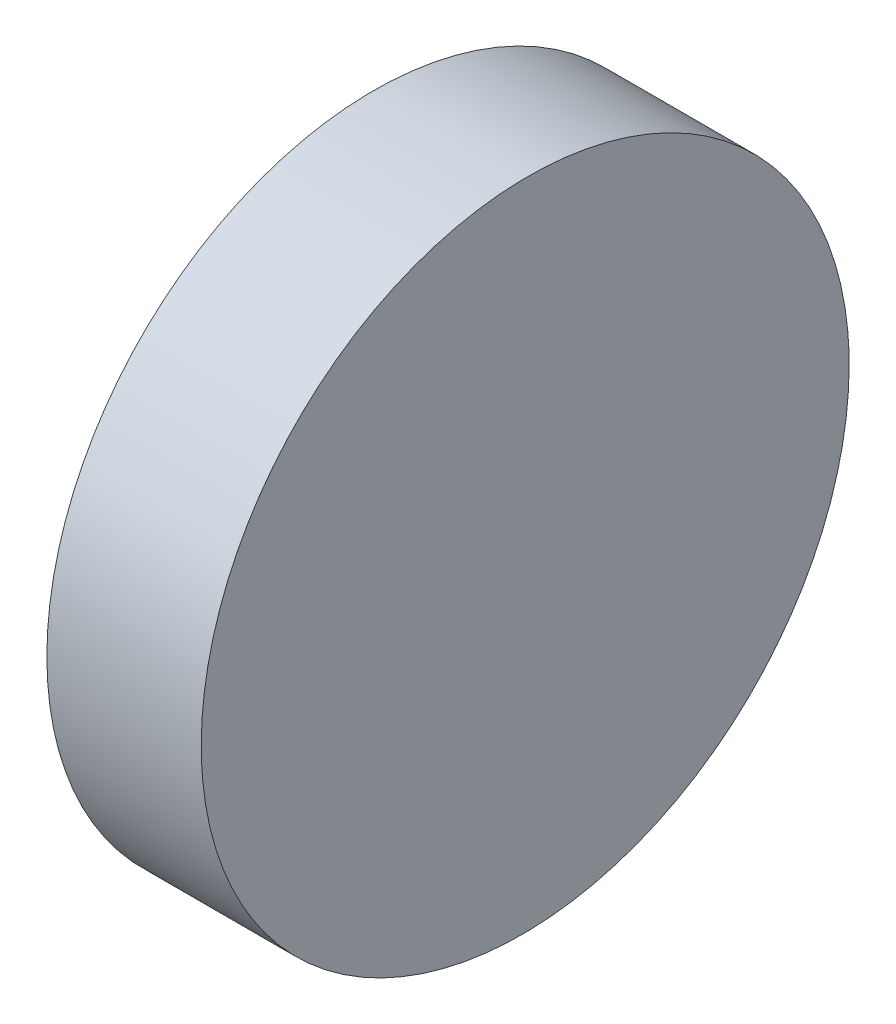
from build123d import *

# Parameters (mm, degrees)
EXTRUDE_1_DEPTH     = 12.7
CUT_EXTRUDE_2_DEPTH = 12.5


with BuildPart() as part:
    # 草图1 → 凸台-拉伸1 (new body)
    with BuildSketch(Plane(origin=(0, 0, 0), x_dir=(1, 0, 0), z_dir=(0, 1, 0))):
        Polygon((0, 6.35), (0, -6.35), (3, -6.35), (2.889168779, 6.35), align=None)
    extrude(amount=EXTRUDE_1_DEPTH)

    # 草图5 → 切除-拉伸2 (cut)
    with BuildSketch(Plane.ZY):
        with BuildLine():
            Line((-6.35, 12.7), (-6.35, 6.35))
            ThreePointArc((-6.35, 6.35), (-4.490128061, 10.840128061), (0, 12.7))
            Line((0, 12.7), (-6.35, 12.7))
        make_face()
        with BuildLine():
            Line((-6.35, 6.35), (-6.35, 0))
            Line((-6.35, 0), (0, 0))
            ThreePointArc((0, 0), (-4.490128061, 1.859871939), (-6.35, 6.35))
        make_face()
        with BuildLine():
            ThreePointArc((6.35, 6.35), (4.490128061, 1.859871939), (0, 0))
            Line((0, 0), (6.35, 0))
            Line((6.35, 0), (6.35, 6.35))
        make_face()
        with BuildLine():
            ThreePointArc((0, 12.7), (4.490128061, 10.840128061), (6.35, 6.35))
            Line((6.35, 6.35), (6.35, 12.7))
            Line((6.35, 12.7), (0, 12.7))
        make_face()
    extrude(amount=-CUT_EXTRUDE_2_DEPTH, mode=Mode.SUBTRACT)


solid = part.part
